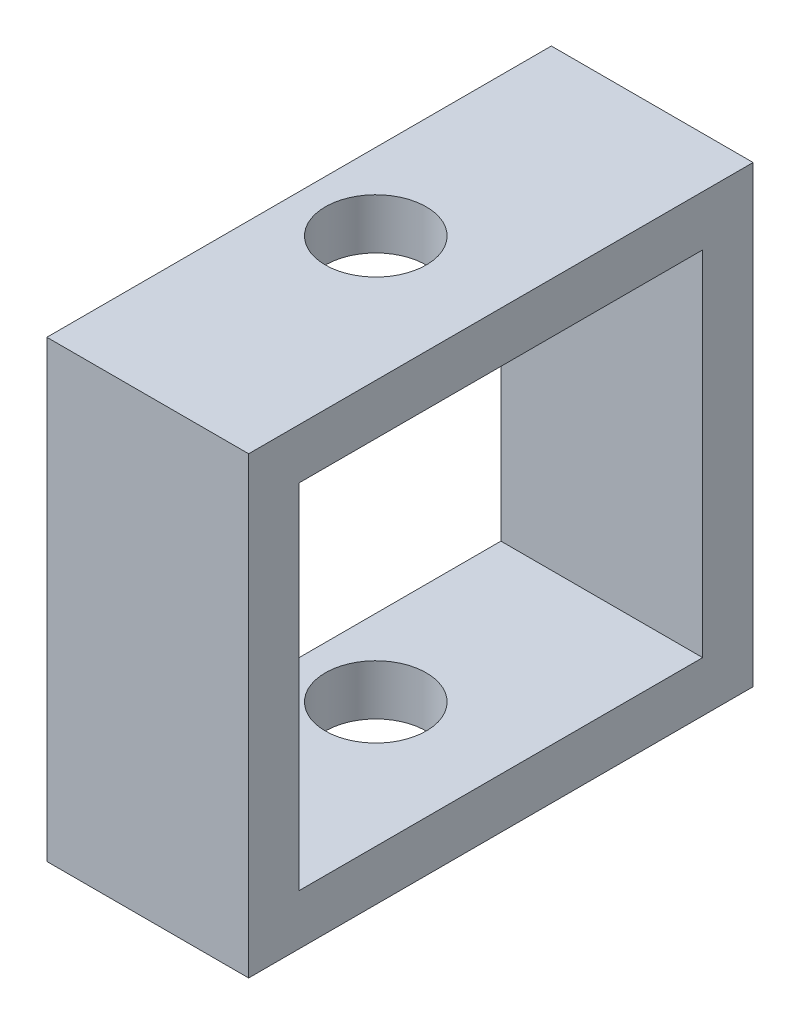
from build123d import *

# Parameters (mm, degrees)
SKETCH1_W           = 12.7
SKETCH1_H           = 31.75
SKETCH1_R           = 3.175
BOSS_EXTRUDE2_DEPTH = 3.175
SKETCH2_W           = 12.7
SKETCH2_H           = 3.175
BOSS_EXTRUDE4_DEPTH = 22.225
SKETCH3_R           = 3.175
BOSS_EXTRUDE5_DEPTH = 3.175


with BuildPart() as part:
    # Sketch1 → Boss-Extrude2 (new body)
    with BuildSketch(Plane(origin=(0, 0, 0), x_dir=(1, 0, 0), z_dir=(0, 1, 0))):
        with Locations((6.35, 15.875)):
            Rectangle(SKETCH1_W, SKETCH1_H)
        with Locations((4.826, 15.875)):
            Circle(SKETCH1_R, mode=Mode.SUBTRACT)
    extrude(amount=BOSS_EXTRUDE2_DEPTH)

    # Sketch2 → Boss-Extrude4 (add)
    with BuildSketch(Plane(origin=(0, 3.175, 0), x_dir=(1, 0, 0), z_dir=(0, 1, 0))):
        Polygon((12.7, 31.75), (0, 31.75), (0, 28.575), (11.684, 28.575), (12.7, 28.575), align=None)
        with Locations((6.35, 1.5875)):
            Rectangle(SKETCH2_W, SKETCH2_H)
    extrude(amount=BOSS_EXTRUDE4_DEPTH)

    # Sketch3 → Boss-Extrude5 (add)
    with BuildSketch(Plane(origin=(0, 25.4, 0), x_dir=(1, 0, 0), z_dir=(0, 1, 0))):
        Polygon((12.7, 28.575), (12.7, 31.75), (0, 31.75), (0, 28.575), (0, 3.175), (0, 0), (12.7, 0), (12.7, 3.175), align=None)
        with Locations((4.826, 15.875)):
            Circle(SKETCH3_R, mode=Mode.SUBTRACT)
    extrude(amount=BOSS_EXTRUDE5_DEPTH)


solid = part.part
